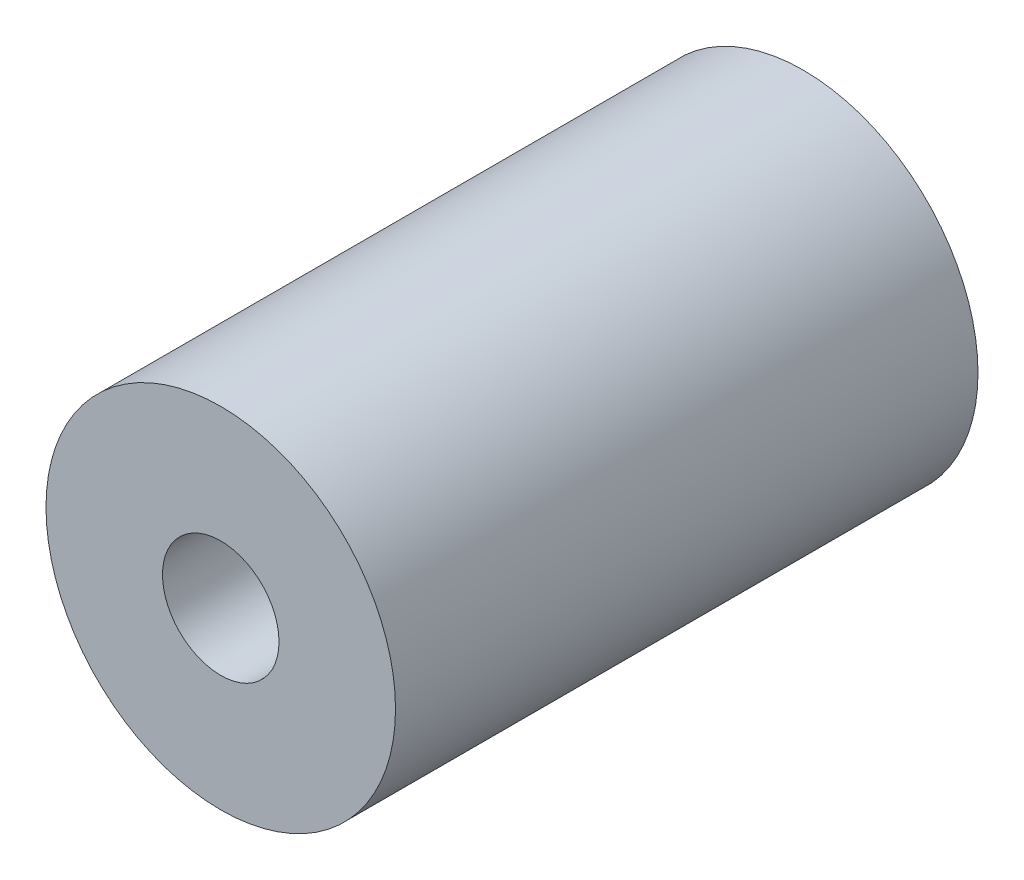
from build123d import *

# Parameters (mm, degrees)
SKETCH_1_R      = 30
SKETCH_1_R_2    = 10
EXTRUDE_1_DEPTH = 100


with BuildPart() as part:
    # Эскиз1 → Бобышка-Вытянуть1 (new body)
    with BuildSketch(Plane.XY):
        Circle(SKETCH_1_R)
        Circle(SKETCH_1_R_2, mode=Mode.SUBTRACT)
    extrude(amount=EXTRUDE_1_DEPTH)


solid = part.part
